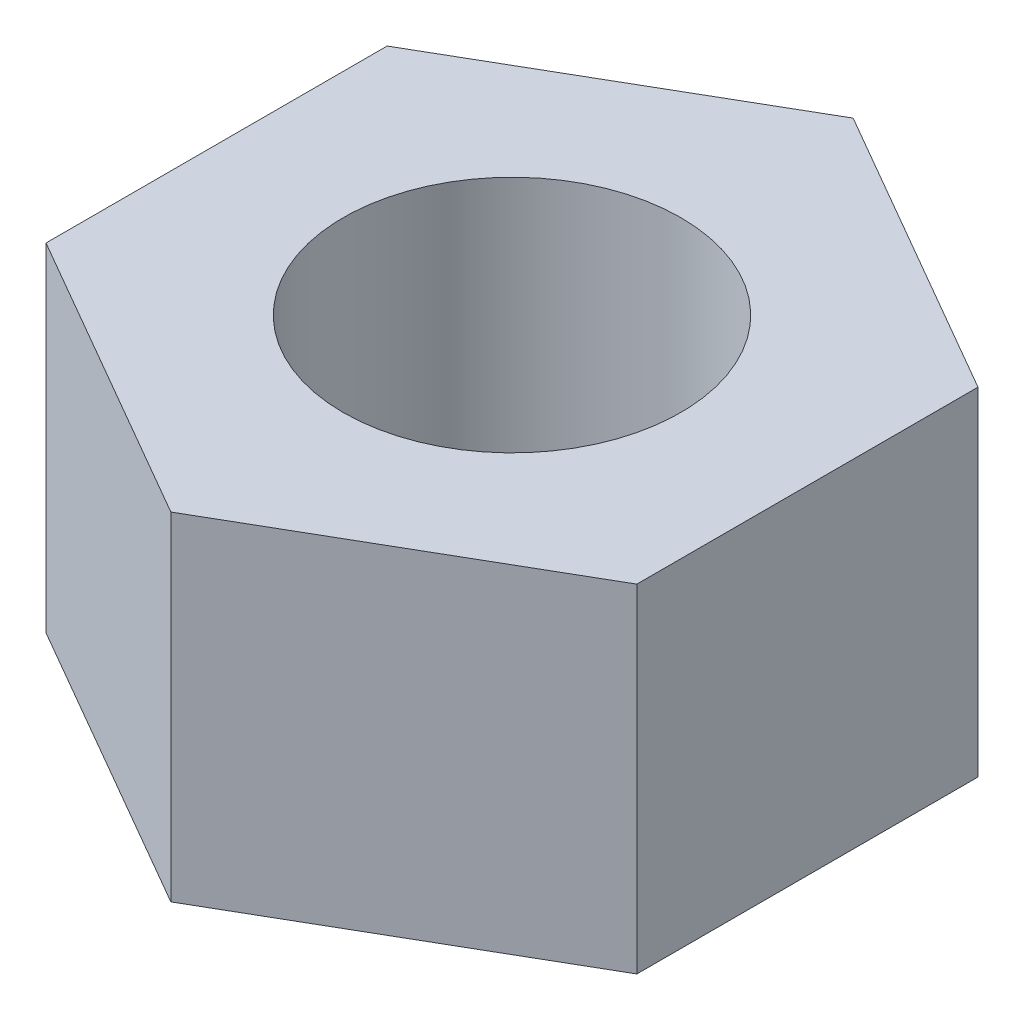
from build123d import *

# Parameters (mm, degrees)
SKETCH1_R           = 2
BOSS_EXTRUDE1_DEPTH = 4


with BuildPart() as part:
    # Sketch1 → Boss-Extrude1 (new body)
    with BuildSketch(Plane(origin=(0, 0, 0), x_dir=(1, 0, 0), z_dir=(0, 1, 0))):
        Polygon((0, -4.041451884), (3.5, -2.020725942), (3.5, 2.020725942), (0, 4.041451884), (-3.5, 2.020725942), (-3.5, -2.020725942), align=None)
        Circle(SKETCH1_R, mode=Mode.SUBTRACT)
    extrude(amount=BOSS_EXTRUDE1_DEPTH)


solid = part.part
